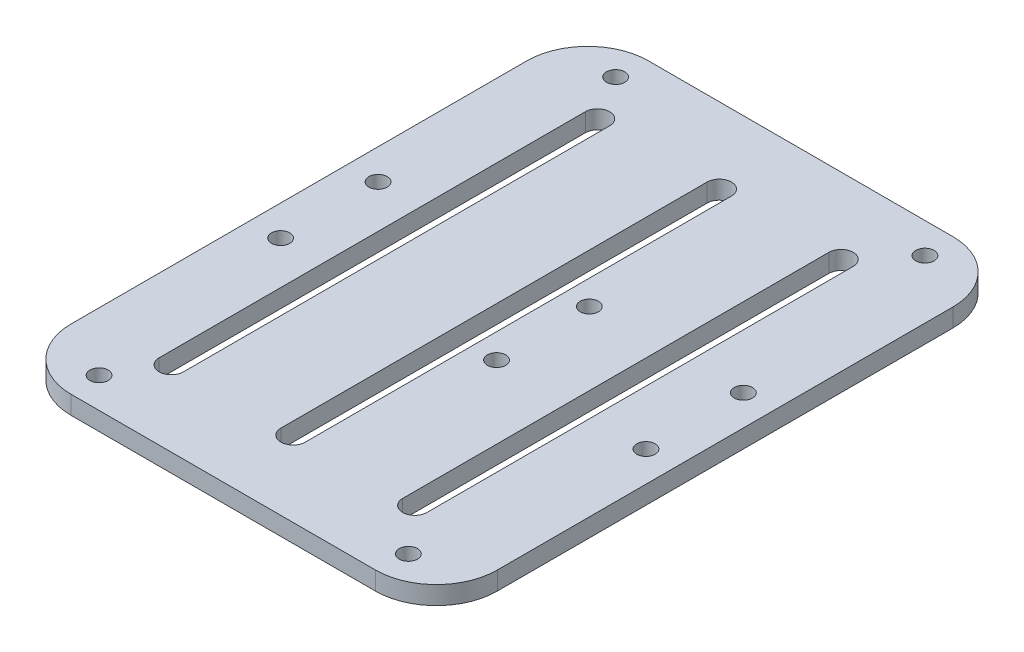
from build123d import *

# Parameters (mm, degrees)
SKETCH_1_R      = 1.5
EXTRUDE_1_DEPTH = 3


with BuildPart() as part:
    # 草图1 → 凸台-拉伸1 (new body)
    with BuildSketch(Plane(origin=(0, 0, 0), x_dir=(1, 0, 0), z_dir=(0, 1, 0))):
        with BuildLine():
            Line((-25, 47.42), (25, 47.42))
            ThreePointArc((25, 47.42), (32.071067812, 44.491067812), (35, 37.42))
            Line((35, 37.42), (35, -37.42))
            ThreePointArc((35, -37.42), (32.071067812, -44.491067812), (25, -47.42))
            Line((25, -47.42), (-25, -47.42))
            ThreePointArc((-25, -47.42), (-32.071067812, -44.491067812), (-35, -37.42))
            Line((-35, -37.42), (-35, 37.42))
            ThreePointArc((-35, 37.42), (-32.071067812, 44.491067812), (-25, 47.42))
        make_face()
        with Locations((-30, 8)):
            Circle(SKETCH_1_R, mode=Mode.SUBTRACT)
        with Locations((30, 8)):
            Circle(SKETCH_1_R, mode=Mode.SUBTRACT)
        with Locations((-30, -8)):
            Circle(SKETCH_1_R, mode=Mode.SUBTRACT)
        with Locations((30, -8)):
            Circle(SKETCH_1_R, mode=Mode.SUBTRACT)
        with Locations((-25.4, 42.42)):
            Circle(SKETCH_1_R, mode=Mode.SUBTRACT)
        with Locations((25.4, 42.42)):
            Circle(SKETCH_1_R, mode=Mode.SUBTRACT)
        with Locations((-25.4, -42.42)):
            Circle(SKETCH_1_R, mode=Mode.SUBTRACT)
        with Locations((25.4, -42.42)):
            Circle(SKETCH_1_R, mode=Mode.SUBTRACT)
        with Locations((5.08, -7.62)):
            Circle(SKETCH_1_R, mode=Mode.SUBTRACT)
        with Locations((5.08, 7.62)):
            Circle(SKETCH_1_R, mode=Mode.SUBTRACT)
        with BuildLine():
            Line((-22.95709571, -35), (-22.95709571, 35))
            ThreePointArc((-22.95709571, 35), (-20.95709571, 37), (-18.95709571, 35))
            Line((-18.95709571, 35), (-18.95709571, -35))
            ThreePointArc((-18.95709571, -35), (-20.95709571, -37), (-22.95709571, -35))
        make_face(mode=Mode.SUBTRACT)
        with BuildLine():
            Line((-2.95709571, -35), (-2.95709571, 35))
            ThreePointArc((-2.95709571, 35), (-0.95709571, 37), (1.04290429, 35))
            Line((1.04290429, 35), (1.04290429, -35))
            ThreePointArc((1.04290429, -35), (-0.95709571, -37), (-2.95709571, -35))
        make_face(mode=Mode.SUBTRACT)
        with BuildLine():
            Line((17.04290429, -35), (17.04290429, 35))
            ThreePointArc((17.04290429, 35), (19.04290429, 37), (21.04290429, 35))
            Line((21.04290429, 35), (21.04290429, -35))
            ThreePointArc((21.04290429, -35), (19.04290429, -37), (17.04290429, -35))
        make_face(mode=Mode.SUBTRACT)
    extrude(amount=EXTRUDE_1_DEPTH)


solid = part.part
